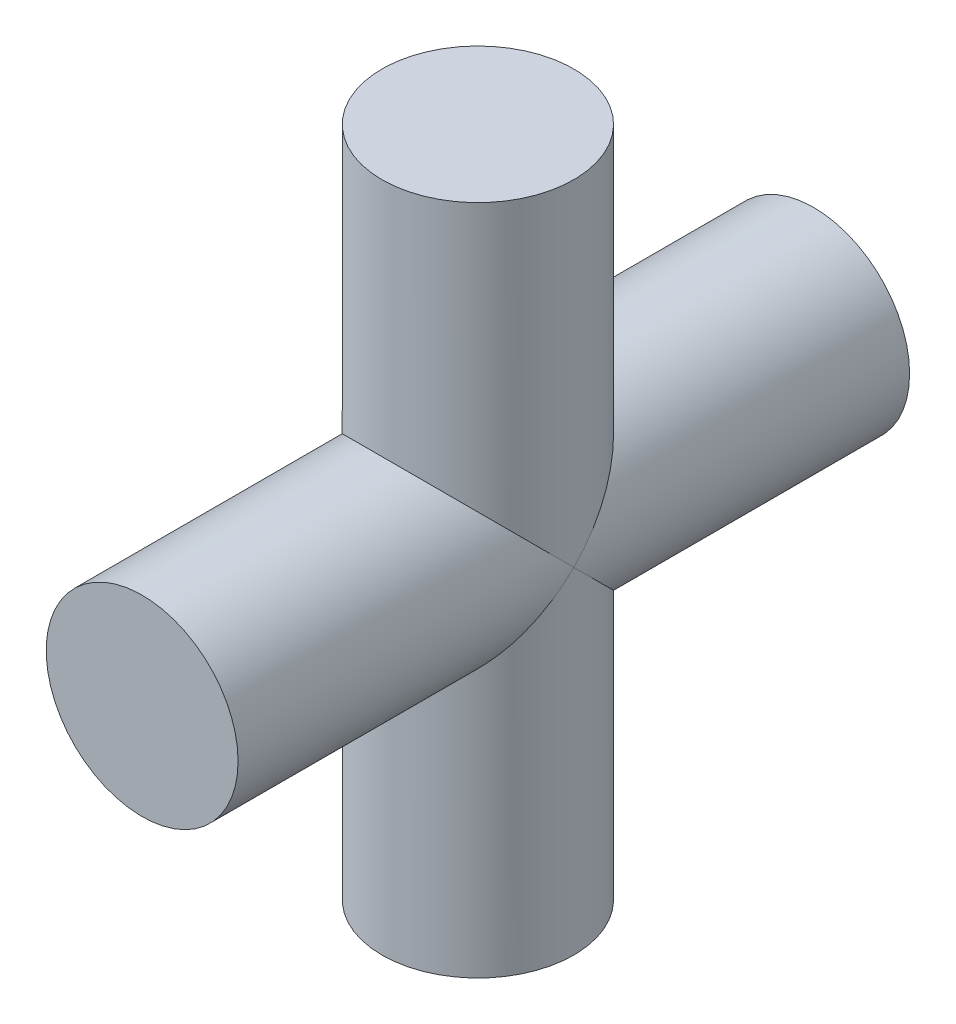
from build123d import *

# Parameters (mm, degrees)
SKETCH1_R                = 3.175
BOSS_EXTRUDE1_DEPTH      = 11.1125
BOSS_EXTRUDE1_DEPTH_BACK = 11.1125
SKETCH2_R                = 3.175
BOSS_EXTRUDE2_DEPTH      = 11.1125
BOSS_EXTRUDE2_DEPTH_BACK = 11.1125


with BuildPart() as part:
    # Sketch1 → Boss-Extrude1 (new body, two sides)
    with BuildSketch(Plane.XY) as boss_extrude1_sk:
        Circle(SKETCH1_R)
    extrude(amount=BOSS_EXTRUDE1_DEPTH)
    extrude(boss_extrude1_sk.sketch, amount=-BOSS_EXTRUDE1_DEPTH_BACK)

    # Sketch2 → Boss-Extrude2 (add, two sides)
    with BuildSketch(Plane(origin=(0, 0, 0), x_dir=(1, 0, 0), z_dir=(0, 1, 0))) as boss_extrude2_sk:
        Circle(SKETCH2_R)
    extrude(amount=BOSS_EXTRUDE2_DEPTH)
    extrude(boss_extrude2_sk.sketch, amount=-BOSS_EXTRUDE2_DEPTH_BACK)


solid = part.part
